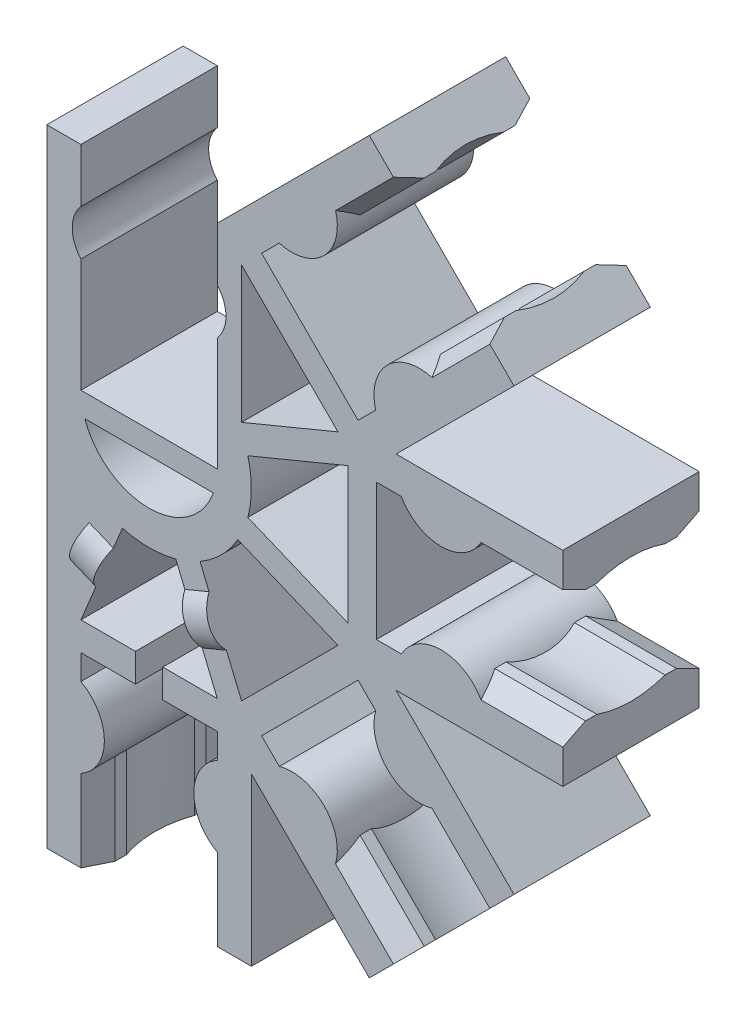
from build123d import *

# Parameters (mm, degrees)
EXTRUDE_1_DEPTH          = 6
EXTRUDE_START            = -3.991967
EXTRUDE_2_DEPTH          = 3.991967
PATTERN_CIRCULAR_1_COUNT = 5
PATTERN_CIRCULAR_1_ANGLE = 180
CUT_EXTRUDE_1_DEPTH      = 7.0000001
EXTRUDE_3_DEPTH          = 1.153683
EXTRUDE_4_DEPTH          = 1.15


with BuildPart() as part:
    # 草图1 → 凸台-拉伸1 (new body)
    with BuildSketch(Plane.XY):
        with BuildLine():
            Line((-4.5, 0), (-4.5, -18.2))
            Line((-4.5, -18.2), (-3, -18.2))
            Line((-3, -18.2), (-3, -14.6))
            ThreePointArc((-3, -14.6), (-1.968245837, -12.85), (-3, -11.1))
            Line((-3, -11.1), (-3, -10))
            Line((-3, -10), (3, -10))
            Line((3, -10), (3, -11.1))
            ThreePointArc((3, -11.1), (1.968245837, -12.85), (3, -14.6))
            Line((3, -14.6), (3, -18.2))
            Line((3, -18.2), (4.5, -18.2))
            Line((4.5, -18.2), (4.5, 0))
            ThreePointArc((4.5, 0), (0, 4.5), (-4.5, 0))
        make_face()
    extrude_1 = extrude(amount=EXTRUDE_1_DEPTH)

    # 草图3 → 凸台-拉伸2 (add)
    with BuildSketch(Plane.XZ.offset(18.2).offset(EXTRUDE_START)):
        with BuildLine():
            Line((-3, 6), (-3, 0))
            Line((-3, 0), (-2.5, 1))
            Line((-2.5, 1), (-2.5, 1.5))
            ThreePointArc((-2.5, 1.5), (-2.757359313, 3), (-2.5, 4.5))
            Line((-2.5, 4.5), (-2.5, 5))
            Line((-2.5, 5), (-3, 6))
        make_face()
        with BuildLine():
            Line((3, 0), (2.5, 1))
            Line((2.5, 1), (2.5, 1.5))
            ThreePointArc((2.5, 1.5), (2.757359313, 3), (2.5, 4.5))
            Line((2.5, 4.5), (2.5, 5))
            Line((2.5, 5), (3, 6))
            Line((3, 6), (3, 0))
        make_face()
    extrude_2 = extrude(amount=EXTRUDE_2_DEPTH)

    # 阵列(圆周)1: 凸台-拉伸1, 凸台-拉伸2 ×5 about axis
    pattern_circular_1_axis = Axis((0, 0, 0), (0, 0, 1))
    for i in range(1, PATTERN_CIRCULAR_1_COUNT):
        add(extrude_1.rotate(pattern_circular_1_axis, i * PATTERN_CIRCULAR_1_ANGLE / (PATTERN_CIRCULAR_1_COUNT - 1)))
        add(extrude_2.rotate(pattern_circular_1_axis, i * PATTERN_CIRCULAR_1_ANGLE / (PATTERN_CIRCULAR_1_COUNT - 1)))

    # 草图4 → 切除-拉伸1 (cut, through all)
    with BuildSketch(Plane(origin=(0, 0, 0), x_dir=(-1, 0, 0), z_dir=(0, 0, -1))):
        with BuildLine():
            Line((-3, -8.75), (-1.174936357, -4.343906601))
            ThreePointArc((-1.174936357, -4.343906601), (0, -4.5), (1.174936357, -4.343906601))
            Line((1.174936357, -4.343906601), (3, -8.75))
            Line((3, -8.75), (0.6, -8.75))
            Line((0.6, -8.75), (0.6, -10))
            Line((0.6, -10), (-0.6, -10))
            Line((-0.6, -10), (-0.6, -8.75))
            Line((-0.6, -8.75), (-3, -8.75))
        make_face()
        with BuildLine():
            Line((-4.065863992, -8.308504679), (-8.308504679, -4.065863992))
            Line((-8.308504679, -4.065863992), (-3.90241128, -2.240800349))
            ThreePointArc((-3.90241128, -2.240800349), (-3.181980515, -3.181980515), (-2.240800349, -3.90241128))
            Line((-2.240800349, -3.90241128), (-4.065863992, -8.308504679))
        make_face()
        with BuildLine():
            Line((-8.75, 3), (-4.343906601, 1.174936357))
            ThreePointArc((-4.343906601, 1.174936357), (-4.5, 0), (-4.343906601, -1.174936357))
            Line((-4.343906601, -1.174936357), (-8.75, -3))
            Line((-8.75, -3), (-8.75, 3))
        make_face()
        Polygon((-8.308504679, 4.065863992), (-4.065863992, 2.308504679), (-4.065863992, 8.308504679), align=None)
        with BuildLine():
            Line((-4.5, 10.863961031), (-3, 9.363961031))
            Line((-3, 9.363961031), (-3, 7))
            ThreePointArc((-3, 7), (-3.381966011, 6), (-3, 5))
            Line((-3, 5), (-3, 0))
            Line((-3, 0), (0, 0))
            Line((0, 0), (3, 0))
            Line((3, 0), (3, 5))
            ThreePointArc((3, 5), (3.381966011, 6), (3, 7))
            Line((3, 7), (3, 9.363961031))
            Line((3, 9.363961031), (4.5, 9.363961031))
            Line((4.5, 9.363961031), (4.5, 18.2))
            Line((4.5, 18.2), (-4.5, 18.2))
            Line((-4.5, 18.2), (-4.5, 10.863961031))
        make_face()
        with BuildLine():
            Line((-2.828427125, -1), (2.828427125, -1))
            ThreePointArc((2.828427125, -1), (0, -3), (-2.828427125, -1))
        make_face()
    extrude(amount=-CUT_EXTRUDE_1_DEPTH, mode=Mode.SUBTRACT)

    # 草图5 → 凸台-拉伸3 (add)
    with BuildSketch(Plane(origin=(-0.532931996, -0.220747661, 0), x_dir=(0, 0, 1), z_dir=(-0.923879533, -0.382683432, 0))):
        with BuildLine():
            Line((0, -7.5), (0, -5.5))
            ThreePointArc((0, -5.5), (-0.381966011, -6.5), (0, -7.5))
        make_face()
        with BuildLine():
            Line((6, -7.5), (6, -5.5))
            ThreePointArc((6, -5.5), (6.381966011, -6.5), (6, -7.5))
        make_face()
    extrude(amount=-EXTRUDE_3_DEPTH)

    # 草图7 → 凸台-拉伸4 (add)
    with BuildSketch(Plane(origin=(0.532931996, -0.220747661, 0), x_dir=(0, 0, -1), z_dir=(0.923879533, -0.382683432, 0))):
        with BuildLine():
            Line((0, -7.5), (0, -5.5))
            ThreePointArc((0, -5.5), (0.381966011, -6.5), (0, -7.5))
        make_face()
        with BuildLine():
            Line((-6, -7.5), (-6, -5.5))
            ThreePointArc((-6, -5.5), (-6.381966011, -6.5), (-6, -7.5))
        make_face()
    extrude(amount=-EXTRUDE_4_DEPTH)


solid = part.part
